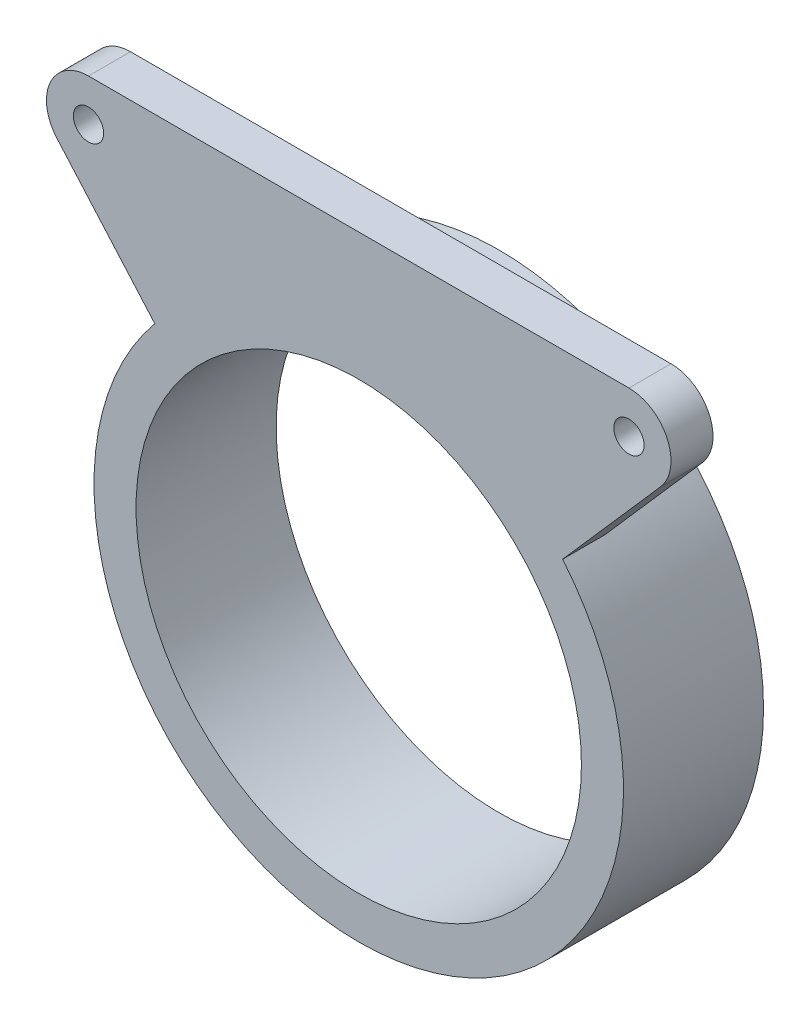
from build123d import *

# Parameters (mm, degrees)
SKETCH1_R           = 23.999
SKETCH1_R_2         = 20.189
BOSS_EXTRUDE1_DEPTH = 12.7
SKETCH2_R           = 1.37499852
BOSS_EXTRUDE2_DEPTH = 3.81


with BuildPart() as part:
    # Sketch1 → Boss-Extrude1 (new body)
    with BuildSketch(Plane.XY):
        Circle(SKETCH1_R)
        Circle(SKETCH1_R_2, mode=Mode.SUBTRACT)
    extrude(amount=BOSS_EXTRUDE1_DEPTH)

    # Sketch2 → Boss-Extrude2 (add)
    with BuildSketch(Plane.XY.offset(12.7)):
        with BuildLine():
            Line((18.486532878, 15.303597719), (27.364357617, 25.428067959))
            ThreePointArc((27.364357617, 25.428067959), (27.970037037, 29.512520099), (24.499694037, 31.75))
            Line((24.499694037, 31.75), (-24.499694037, 31.75))
            ThreePointArc((-24.499694037, 31.75), (-27.970037037, 29.512520099), (-27.364357617, 25.428067959))
            Line((-27.364357617, 25.428067959), (-18.486532878, 15.303597719))
            ThreePointArc((-18.486532878, 15.303597719), (0, 23.999), (18.486532878, 15.303597719))
        make_face()
        with Locations((-24.499694037, 27.94)):
            Circle(SKETCH2_R, mode=Mode.SUBTRACT)
        with Locations((24.499694037, 27.94)):
            Circle(SKETCH2_R, mode=Mode.SUBTRACT)
    extrude(amount=-BOSS_EXTRUDE2_DEPTH)


solid = part.part
